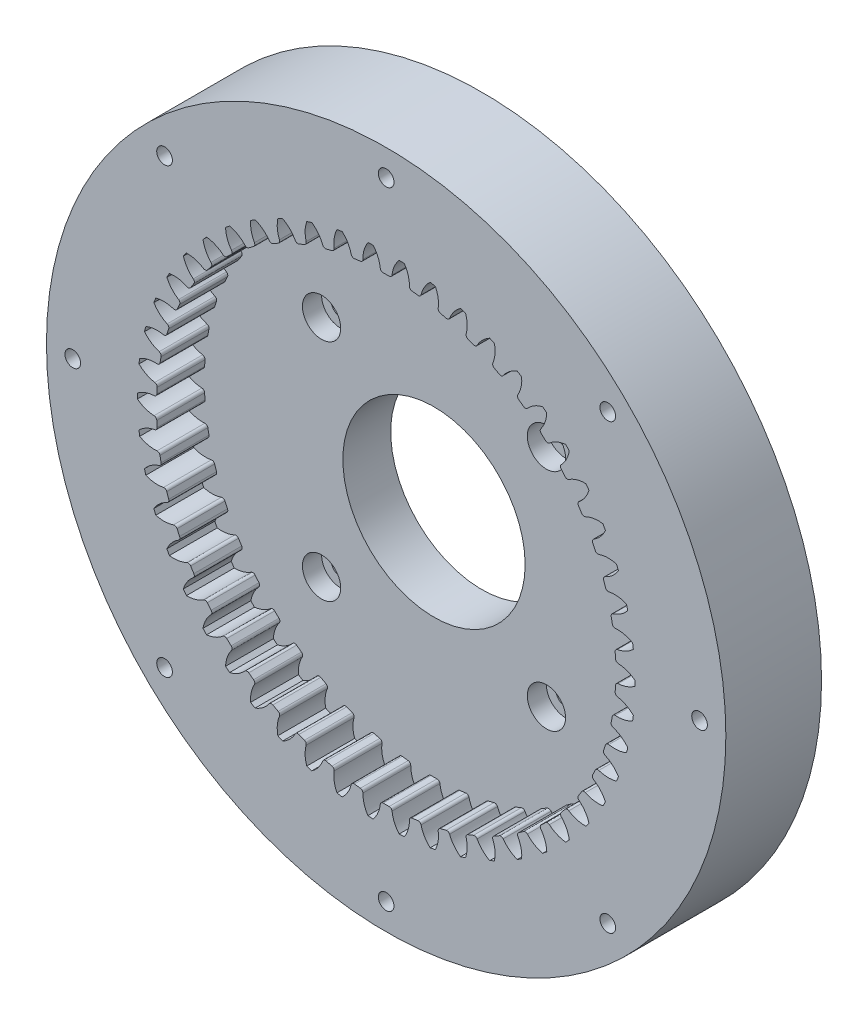
from build123d import *

# Parameters (mm, degrees)
SKETCH1_R           = 60
BOSS_EXTRUDE1_DEPTH = 10
CUT_EXTRUDE2_DEPTH  = 11
CIRPATTERN2_COUNT   = 50
SKETCH6_R           = 48
CUT_EXTRUDE3_DEPTH  = 11
SKETCH7_R           = 60
BOSS_EXTRUDE2_DEPTH = 10
SKETCH8_R           = 19.05
SKETCH8_R_2         = 2
CUT_EXTRUDE4_DEPTH  = 11
SKETCH9_R           = 4
CUT_EXTRUDE5_DEPTH  = 4
SKETCH10_R          = 71
SKETCH10_R_2        = 1.63703
SKETCH10_R_3        = 60
BOSS_EXTRUDE3_DEPTH = 20
CUT_EXTRUDE6_DEPTH  = 10.3114
CIRPATTERN3_COUNT   = 8


with BuildPart() as part:
    # Sketch1 → Boss-Extrude1 (new body)
    with BuildSketch(Plane.XY):
        Circle(SKETCH1_R)
    extrude(amount=BOSS_EXTRUDE1_DEPTH)

    # Sketch5 → Cut-Extrude2 (cut, through all)
    with BuildSketch(Plane(origin=(0, 0, 0), x_dir=(-1, 0, 0), z_dir=(0, 0, -1))):
        with BuildLine():
            ThreePointArc((2.716613684, 51.928990074), (1.716892954, 50.341251638), (1.231241814, 48.528933275))
            ThreePointArc((1.231241814, 48.528933275), (1.031960133, 48.145950609), (0.627145887, 47.995902826))
            ThreePointArc((0.627145887, 47.995902826), (3.013944937, 47.905282965), (5.393281044, 47.696043018))
            ThreePointArc((5.393281044, 47.696043018), (5.010464854, 47.895644308), (4.860755025, 48.300583659))
            ThreePointArc((4.860755025, 48.300583659), (4.606077109, 50.159479578), (3.813235868, 51.859996454))
            ThreePointArc((3.813235868, 51.859996454), (3.265107016, 51.897389878), (2.716613684, 51.928990074))
        make_face()
    cut_extrude2 = extrude(amount=-CUT_EXTRUDE2_DEPTH, mode=Mode.SUBTRACT)

    # CirPattern2: Cut-Extrude2 ×50 about axis
    cirpattern2_axis = Axis((0, 0, 0), (0, 0, 1))
    for i in range(1, CIRPATTERN2_COUNT):
        add(cut_extrude2.rotate(cirpattern2_axis, i * 360 / CIRPATTERN2_COUNT), mode=Mode.SUBTRACT)

    # Sketch6 → Cut-Extrude3 (cut, through all)
    with BuildSketch(Plane(origin=(0, 0, 0), x_dir=(-1, 0, 0), z_dir=(0, 0, -1))):
        Circle(SKETCH6_R)
    extrude(amount=-CUT_EXTRUDE3_DEPTH, mode=Mode.SUBTRACT)

    # Sketch7 → Boss-Extrude2 (add)
    with BuildSketch(Plane(origin=(0, 0, 0), x_dir=(-1, 0, 0), z_dir=(0, 0, -1))):
        Circle(SKETCH7_R)
    extrude(amount=BOSS_EXTRUDE2_DEPTH)

    # Sketch8 → Cut-Extrude4 (cut, through all)
    with BuildSketch(Plane.XY):
        Circle(SKETCH8_R)
        with Locations((-23.5, 23.5)):
            Circle(SKETCH8_R_2)
        with Locations((23.5, 23.5)):
            Circle(SKETCH8_R_2)
        with Locations((23.5, -23.5)):
            Circle(SKETCH8_R_2)
        with Locations((-23.5, -23.5)):
            Circle(SKETCH8_R_2)
    extrude(amount=-CUT_EXTRUDE4_DEPTH, mode=Mode.SUBTRACT)

    # Sketch9 → Cut-Extrude5 (cut)
    with BuildSketch(Plane.XY):
        with Locations((-23.5, 23.5)):
            Circle(SKETCH9_R)
        with Locations((23.5, 23.5)):
            Circle(SKETCH9_R)
        with Locations((23.5, -23.5)):
            Circle(SKETCH9_R)
        with Locations((-23.5, -23.5)):
            Circle(SKETCH9_R)
    extrude(amount=-CUT_EXTRUDE5_DEPTH, mode=Mode.SUBTRACT)

    # Sketch10 → Boss-Extrude3 (add, through all)
    with BuildSketch(Plane(origin=(0, 0, -10), x_dir=(-1, 0, 0), z_dir=(0, 0, -1))):
        Circle(SKETCH10_R)
        with Locations((0, 65.5)):
            Circle(SKETCH10_R_2, mode=Mode.SUBTRACT)
        with Locations((46.315494168, 46.315494168)):
            Circle(SKETCH10_R_2, mode=Mode.SUBTRACT)
        with Locations((65.5, 0)):
            Circle(SKETCH10_R_2, mode=Mode.SUBTRACT)
        with Locations((46.315494168, -46.315494168)):
            Circle(SKETCH10_R_2, mode=Mode.SUBTRACT)
        with Locations((0, -65.5)):
            Circle(SKETCH10_R_2, mode=Mode.SUBTRACT)
        with Locations((-46.315494168, -46.315494168)):
            Circle(SKETCH10_R_2, mode=Mode.SUBTRACT)
        with Locations((-65.5, 0)):
            Circle(SKETCH10_R_2, mode=Mode.SUBTRACT)
        with Locations((-46.315494168, 46.315494168)):
            Circle(SKETCH10_R_2, mode=Mode.SUBTRACT)
        Circle(SKETCH10_R_3, mode=Mode.SUBTRACT)
    extrude(amount=-BOSS_EXTRUDE3_DEPTH)

    # Sketch11 → Cut-Extrude6 (cut)
    with BuildSketch(Plane(origin=(0, 0, -10), x_dir=(-1, 0, 0), z_dir=(0, 0, -1))):
        Polygon((-3.643750216, 65.71423953), (-2.007411984, 62.451539513), (1.636338232, 62.237299983), (3.643750216, 65.28576047), (2.007411984, 68.548460487), (-1.636338232, 68.762700017), align=None)
    cut_extrude6 = extrude(amount=-CUT_EXTRUDE6_DEPTH, mode=Mode.SUBTRACT)

    # CirPattern3: Cut-Extrude6 ×8 about axis
    cirpattern3_axis = Axis((0, 0, 0), (0, 0, 1))
    for i in range(1, CIRPATTERN3_COUNT):
        add(cut_extrude6.rotate(cirpattern3_axis, i * 360 / CIRPATTERN3_COUNT), mode=Mode.SUBTRACT)


solid = part.part
